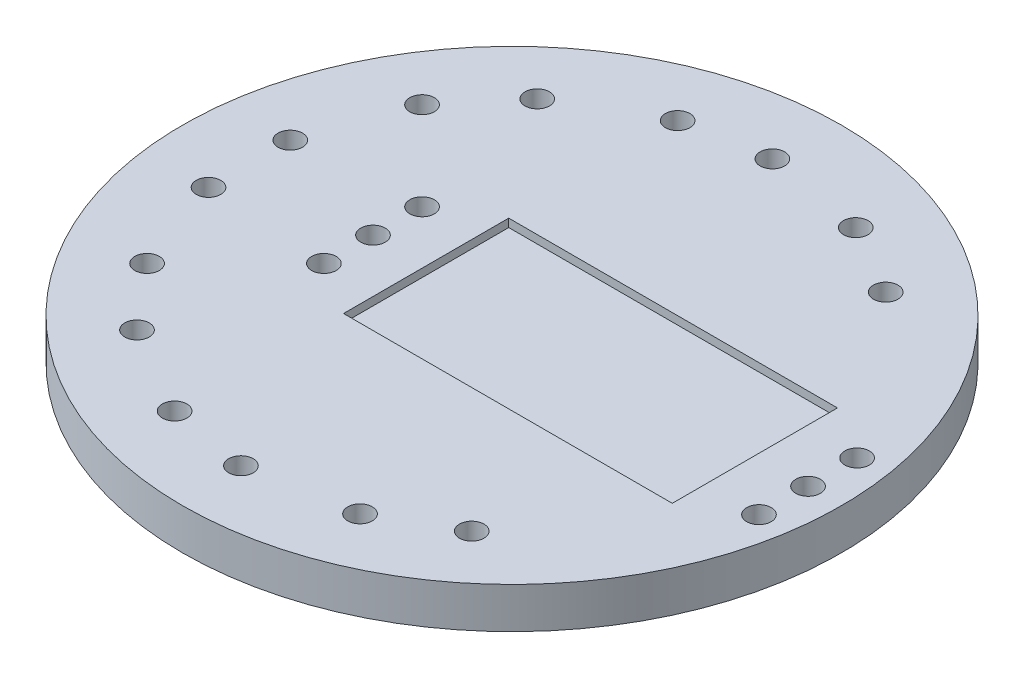
from build123d import *

# Parameters (mm, degrees)
SKETCH1_R           = 40.3
BOSS_EXTRUDE1_DEPTH = 5
SKETCH2_W           = 40.2
SKETCH2_H           = 20.2
CUT_EXTRUDE3_DEPTH  = 1
SKETCH3_R           = 1.5
CUT_EXTRUDE4_DEPTH  = 6
CUT_EXTRUDE5_REACH  = 7
SKETCH4_R           = 1.5
SKETCH5_R           = 1.5
CUT_EXTRUDE6_DEPTH  = 6


with BuildPart() as part:
    # Sketch1 → Boss-Extrude1 (new body)
    with BuildSketch(Plane(origin=(0, 0, 0), x_dir=(1, 0, 0), z_dir=(0, 1, 0))):
        Circle(SKETCH1_R)
    extrude(amount=BOSS_EXTRUDE1_DEPTH)

    # Sketch2 → Cut-Extrude3 (cut)
    with BuildSketch(Plane(origin=(0, 5, 0), x_dir=(1, 0, 0), z_dir=(0, 1, 0))):
        with Locations((9.6, 0)):
            Rectangle(SKETCH2_W, SKETCH2_H)
    extrude(amount=-CUT_EXTRUDE3_DEPTH, mode=Mode.SUBTRACT)

    # Sketch3 → Cut-Extrude4 (cut, through all)
    with BuildSketch(Plane(origin=(0, 5, 0), x_dir=(1, 0, 0), z_dir=(0, 1, 0))):
        with Locations((-17, -6)):
            Circle(SKETCH3_R)
        with Locations((-17, 0)):
            Circle(SKETCH3_R)
        with Locations((-17, 6)):
            Circle(SKETCH3_R)
        with Locations((36.2, -6)):
            Circle(SKETCH3_R)
        with Locations((36.2, 0)):
            Circle(SKETCH3_R)
        with Locations((36.2, 6)):
            Circle(SKETCH3_R)
    extrude(amount=-CUT_EXTRUDE4_DEPTH, mode=Mode.SUBTRACT)

    # Sketch4 → Cut-Extrude5 (cut, up to next)
    with BuildSketch(Plane(origin=(0, 5, 0), x_dir=(1, 0, 0), z_dir=(0, 1, 0)), mode=Mode.PRIVATE) as cut_extrude5_sk1:
        with Locations((-32.113081447, 5)):
            Circle(SKETCH4_R)
    cut_extrude5_tool1 = extrude(cut_extrude5_sk1.sketch, amount=-CUT_EXTRUDE5_REACH, mode=Mode.PRIVATE) & part.part
    add(cut_extrude5_tool1.solids().sort_by_distance((-32.113081, 5, -5))[0], mode=Mode.SUBTRACT)
    # Sketch4 → Cut-Extrude5 (cut, up to next)
    with BuildSketch(Plane(origin=(0, 5, 0), x_dir=(1, 0, 0), z_dir=(0, 1, 0)), mode=Mode.PRIVATE) as cut_extrude5_sk2:
        with Locations((-32.113081447, -5)):
            Circle(SKETCH4_R)
    cut_extrude5_tool2 = extrude(cut_extrude5_sk2.sketch, amount=-CUT_EXTRUDE5_REACH, mode=Mode.PRIVATE) & part.part
    add(cut_extrude5_tool2.solids().sort_by_distance((-32.113081, 5, 5))[0], mode=Mode.SUBTRACT)

    # Sketch5 → Cut-Extrude6 (cut, through all)
    with BuildSketch(Plane(origin=(0, 5, 0), x_dir=(1, 0, 0), z_dir=(0, 1, 0))):
        with Locations((-32.113081447, 5)):
            Circle(SKETCH5_R)
        with Locations((-32.113081447, -5)):
            Circle(SKETCH5_R)
        with Locations((-21.386109545, 24.472113078)):
            Circle(SKETCH5_R)
        with Locations((-27.813985642, 16.811668647)):
            Circle(SKETCH5_R)
        with Locations((-0.652339307, 32.49345247)):
            Circle(SKETCH5_R)
        with Locations((-10.500416838, 30.756970693)):
            Circle(SKETCH5_R)
        with Locations((20.386667742, 25.310744327)):
            Circle(SKETCH5_R)
        with Locations((11.726413704, 30.310744327)):
            Circle(SKETCH5_R)
        with Locations((-27.813985642, -16.811668647)):
            Circle(SKETCH5_R)
        with Locations((-21.386109545, -24.472113078)):
            Circle(SKETCH5_R)
        with Locations((-10.500416838, -30.756970693)):
            Circle(SKETCH5_R)
        with Locations((-0.652339307, -32.49345247)):
            Circle(SKETCH5_R)
        with Locations((11.726413704, -30.310744327)):
            Circle(SKETCH5_R)
        with Locations((20.386667742, -25.310744327)):
            Circle(SKETCH5_R)
    extrude(amount=-CUT_EXTRUDE6_DEPTH, mode=Mode.SUBTRACT)


solid = part.part
